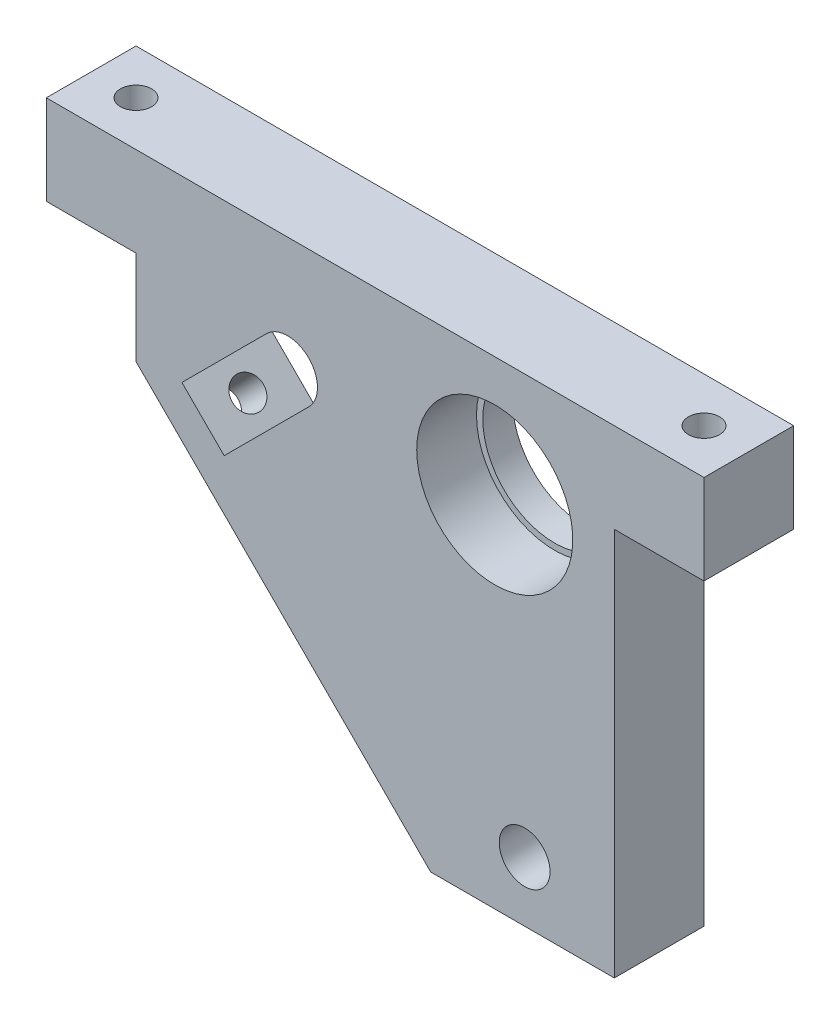
from build123d import *

# Parameters (mm, degrees)
SKETCH_1_R          = 12
SKETCH_1_R_2        = 4.25
EXTRUDE_1_DEPTH     = 15
SKETCH_2_R          = 13.05
CUT_EXTRUDE_1_DEPTH = 10
SKETCH_3_R          = 2.6
CUT_EXTRUDE_2_DEPTH = 81
SKETCH_5_R          = 2.6
CUT_EXTRUDE_3_DEPTH = 10


with BuildPart() as part:
    # 草图1 → 凸台-拉伸1 (new body)
    with BuildSketch(Plane.XY):
        Polygon((-33.800989673, 26.383498279), (-27.44059998, 26.383498279), (-18.800989673, 26.383498279), (-18.800989673, 10.67282016), (30.488332208, -38.616501721), (61.199010327, -38.616501721), (61.199010327, 26.383498279), (76.199010327, 26.383498279), (76.199010327, 41.383498279), (56.199010327, 41.383498279), (-33.800989673, 41.383498279), align=None)
        with Locations((41.199010327, 21.383498279)):
            Circle(SKETCH_1_R, mode=Mode.SUBTRACT)
        with Locations((46.199010327, -28.616501721)):
            Circle(SKETCH_1_R_2, mode=Mode.SUBTRACT)
        with BuildLine():
            Line((-11.126891481, 11.484003342), (3.015244143, 25.626138966))
            ThreePointArc((3.015244143, 25.626138966), (10.086311955, 25.626138966), (10.086311955, 18.555071154))
            Line((10.086311955, 18.555071154), (-4.055823669, 4.41293553))
            Line((-4.055823669, 4.41293553), (-11.126891481, 11.484003342))
        make_face(mode=Mode.SUBTRACT)
    extrude(amount=EXTRUDE_1_DEPTH)

    # 草图2 → 切除-拉伸1 (cut)
    with BuildSketch(Plane(origin=(0, 0, 15), x_dir=(-1, 0, 0), z_dir=(0, 0, -1))):
        with Locations((-41.199010327, 21.383498279)):
            Circle(SKETCH_2_R)
    extrude(amount=CUT_EXTRUDE_1_DEPTH, mode=Mode.SUBTRACT)

    # 草图3 → 切除-拉伸2 (cut, through all)
    with BuildSketch(Plane(origin=(0, 41.383498279, 0), x_dir=(1, 0, 0), z_dir=(0, 1, 0))):
        with Locations((-26.300989673, -7.5)):
            Circle(SKETCH_3_R)
        with Locations((68.699010327, -7.5)):
            Circle(SKETCH_3_R)
    extrude(amount=-CUT_EXTRUDE_2_DEPTH, mode=Mode.SUBTRACT)

    # 草图5 → 切除-拉伸3 (cut)
    with BuildSketch(Plane(origin=(-4.064084756, -4.064084756, 0), x_dir=(0, 0, 1), z_dir=(-0.707106781, -0.707106781, 0))):
        with Locations((7.5, 10.9911308)):
            Circle(SKETCH_5_R)
    extrude(amount=-CUT_EXTRUDE_3_DEPTH, mode=Mode.SUBTRACT)


solid = part.part
